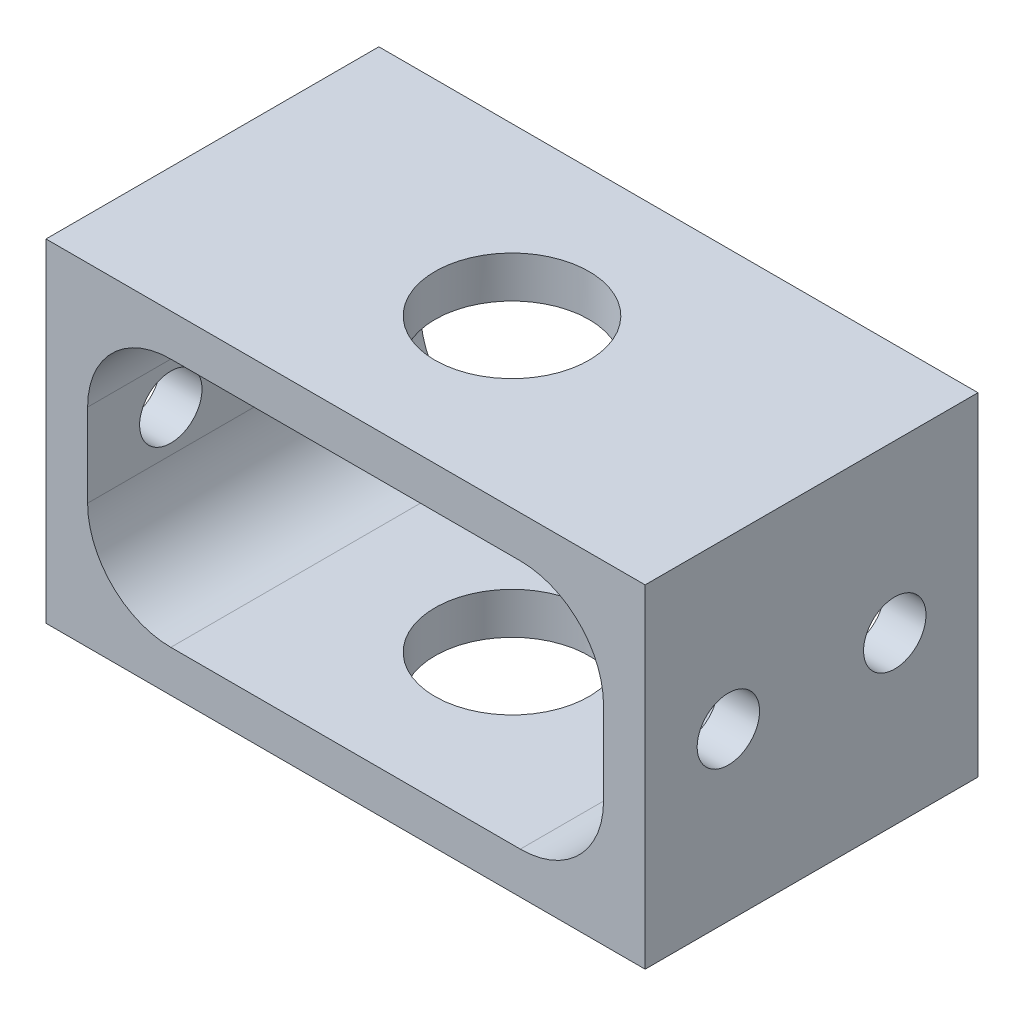
from build123d import *

# Parameters (mm, degrees)
SKETCH_1_W          = 28.8
SKETCH_1_H          = 16
SKETCH_1_W_2        = 24.8
SKETCH_1_H_2        = 12
EXTRUDE_1_DEPTH     = 16
SKETCH_2_R          = 1.5
CUT_EXTRUDE_1_DEPTH = 28.8
SKETCH_3_R          = 3.7
CUT_EXTRUDE_2_DEPTH = 16
FILLET_1_R          = 4


with BuildPart() as part:
    # 草图1 → 凸台-拉伸1 (new body)
    with BuildSketch(Plane.XY):
        Rectangle(SKETCH_1_W, SKETCH_1_H)
        Rectangle(SKETCH_1_W_2, SKETCH_1_H_2, mode=Mode.SUBTRACT)
    extrude(amount=EXTRUDE_1_DEPTH)

    # 草图2 → 切除-拉伸1 (cut)
    with BuildSketch(Plane(origin=(14.4, 0, 0), x_dir=(0, 0, -1), z_dir=(1, 0, 0))):
        with Locations((-12, 0)):
            Circle(SKETCH_2_R)
        with Locations((-4, 0)):
            Circle(SKETCH_2_R)
    extrude(amount=-CUT_EXTRUDE_1_DEPTH, mode=Mode.SUBTRACT)

    # 草图3 → 切除-拉伸2 (cut)
    with BuildSketch(Plane(origin=(0, 8, 0), x_dir=(1, 0, 0), z_dir=(0, 1, 0))):
        with Locations((0, -8)):
            Circle(SKETCH_3_R)
    extrude(amount=-CUT_EXTRUDE_2_DEPTH, mode=Mode.SUBTRACT)

    # 圆角1
    fillet_1_edges = [part.edges().sort_by_distance(p)[0] for p in [
        (12.4, -6, 8),
        (12.4, 6, 8),
        (-12.4, 6, 8),
        (-12.4, -6, 8),
    ]]
    fillet(fillet_1_edges, radius=FILLET_1_R)


solid = part.part
